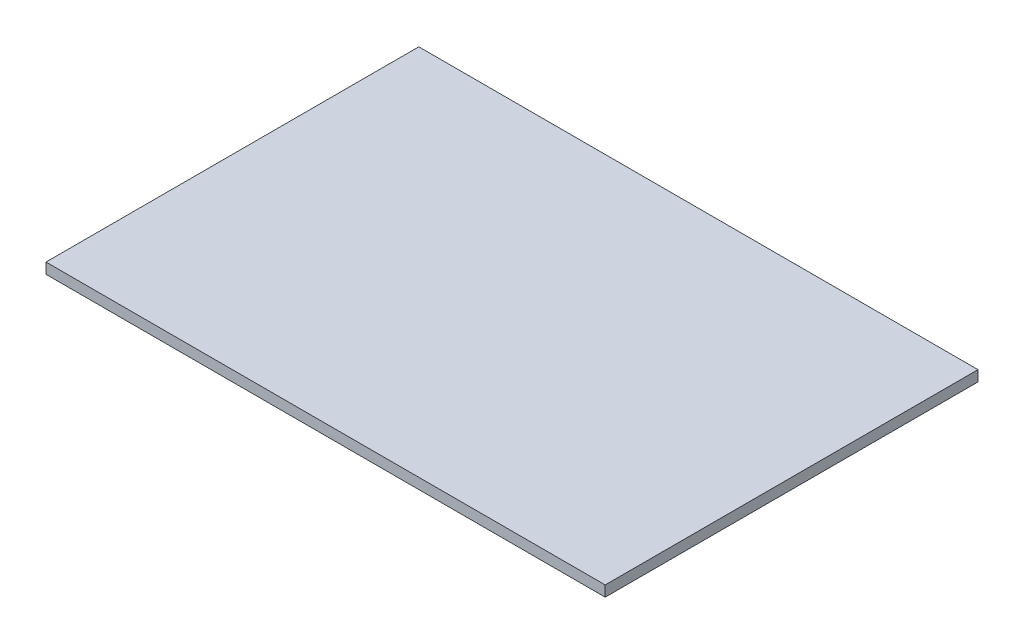
from build123d import *

# Parameters (mm, degrees)
SKETCH1_W           = 105
SKETCH1_H           = 70
BOSS_EXTRUDE1_DEPTH = 2


with BuildPart() as part:
    # Sketch1 → Boss-Extrude1 (new body)
    with BuildSketch(Plane(origin=(0, 0, 0), x_dir=(1, 0, 0), z_dir=(0, 1, 0))):
        Rectangle(SKETCH1_W, SKETCH1_H)
    extrude(amount=BOSS_EXTRUDE1_DEPTH)


solid = part.part
